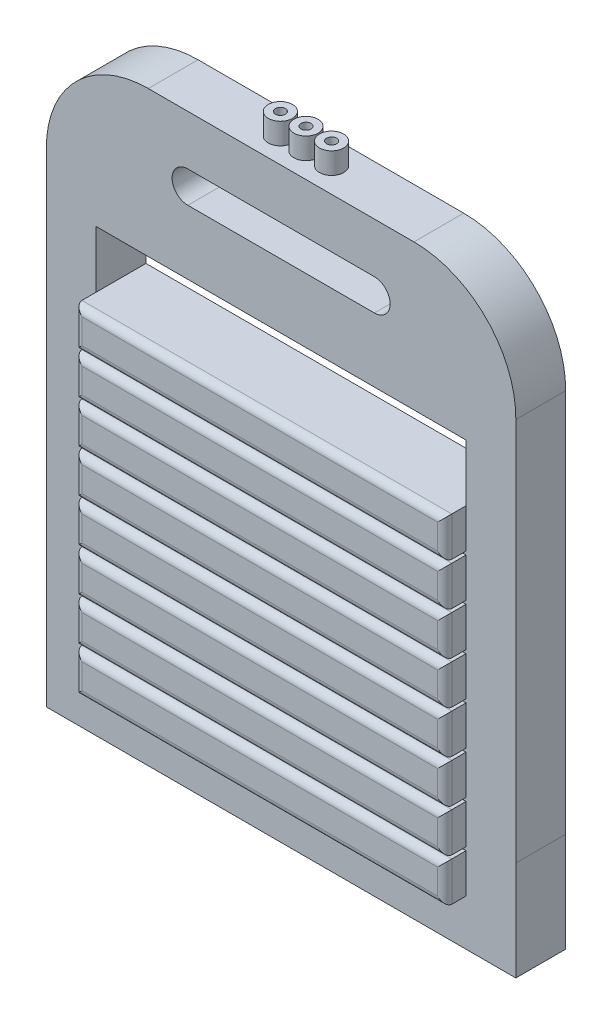
from build123d import *

# Parameters (mm, degrees)
SKETCH1_W           = 660
SKETCH1_H           = 400
BOSS_EXTRUDE1_DEPTH = 70
SKETCH2_W           = 70
SKETCH2_H           = 70
BOSS_EXTRUDE2_DEPTH = 140
SKETCH3_W           = 70
SKETCH3_H           = 60
BOSS_EXTRUDE3_DEPTH = 660
BOSS_EXTRUDE4_DEPTH = 70
SKETCH5_W           = 520
SKETCH5_H           = 55.194253578
BOSS_EXTRUDE5_DEPTH = 30
FILLET1_R           = 10
SKETCH6_R           = 17
SKETCH6_R_2         = 7
BOSS_EXTRUDE6_DEPTH = 30
SKETCH9_W           = 660.000414718
SKETCH9_H           = 140
BOSS_EXTRUDE7_DEPTH = 70
SKETCH10_W          = 520
SKETCH10_H          = 55.194253578
BOSS_EXTRUDE8_DEPTH = 30
FILLET2_R           = 10


with BuildPart() as part:
    # Sketch1 → Boss-Extrude1 (new body)
    with BuildSketch(Plane.XY):
        Rectangle(SKETCH1_W, SKETCH1_H)
    extrude(amount=BOSS_EXTRUDE1_DEPTH)

    # Sketch2 → Boss-Extrude2 (add)
    with BuildSketch(Plane(origin=(0, 200, 0), x_dir=(1, 0, 0), z_dir=(0, 1, 0))):
        with Locations((-295, -35)):
            Rectangle(SKETCH2_W, SKETCH2_H)
        with Locations((295, -35)):
            Rectangle(SKETCH2_W, SKETCH2_H)
    extrude(amount=BOSS_EXTRUDE2_DEPTH)

    # Sketch3 → Boss-Extrude3 (add)
    with BuildSketch(Plane(origin=(330, 0, 0), x_dir=(0, 0, -1), z_dir=(1, 0, 0))):
        with Locations((-35, 310)):
            Rectangle(SKETCH3_W, SKETCH3_H)
    extrude(amount=-BOSS_EXTRUDE3_DEPTH)

    # Sketch4 → Boss-Extrude4 (add)
    with BuildSketch(Plane.XY.offset(70)):
        with BuildLine():
            Line((-186.732097713, 484.618446846), (186.732097713, 484.618446846))
            ThreePointArc((186.732097713, 484.618446846), (288.516412558, 442.178022701), (330, 340))
            Line((330, 340), (-330, 340))
            ThreePointArc((-330, 340), (-288.516412558, 442.178022701), (-186.732097713, 484.618446846))
        make_face()
        with BuildLine():
            Line((-131.145584022, 414.4805226), (131.145584022, 414.4805226))
            ThreePointArc((131.145584022, 414.4805226), (153.253905114, 392.372201507), (131.145584022, 370.263880415))
            Line((131.145584022, 370.263880415), (-131.145584022, 370.263880415))
            ThreePointArc((-131.145584022, 370.263880415), (-153.253905114, 392.372201507), (-131.145584022, 414.4805226))
        make_face(mode=Mode.SUBTRACT)
    extrude(amount=-BOSS_EXTRUDE4_DEPTH)

    # Sketch5 → Boss-Extrude5 (add)
    with BuildSketch(Plane.XY.offset(70)):
        with Locations((0, 172.402873211)):
            Rectangle(SKETCH5_W, SKETCH5_H)
        with Locations((0, 112.402873211)):
            Rectangle(SKETCH5_W, SKETCH5_H)
        with Locations((0, 52.402873211)):
            Rectangle(SKETCH5_W, SKETCH5_H)
        with Locations((0, -7.597126789)):
            Rectangle(SKETCH5_W, SKETCH5_H)
        with Locations((0, -67.597126789)):
            Rectangle(SKETCH5_W, SKETCH5_H)
        with Locations((0, -127.597126789)):
            Rectangle(SKETCH5_W, SKETCH5_H)
    extrude(amount=BOSS_EXTRUDE5_DEPTH)

    # Fillet1
    fillet1_edges = [part.edges().sort_by_distance(p)[0] for p in [
        (0, 140, 100),
        (-260, 112.402873211, 100),
        (0, 84.805746422, 100),
        (260, 112.402873211, 100),
        (0, 80, 100),
        (-260, 52.402873211, 100),
        (0, 24.805746422, 100),
        (260, 52.402873211, 100),
        (0, 20, 100),
        (-260, -7.597126789, 100),
        (0, -35.194253578, 100),
        (260, -7.597126789, 100),
        (0, -40, 100),
        (-260, -67.597126789, 100),
        (0, -95.194253578, 100),
        (260, -67.597126789, 100),
        (0, -100, 100),
        (-260, -127.597126789, 100),
        (0, -155.194253578, 100),
        (260, -127.597126789, 100),
        (-260, 172.402873211, 100),
        (0, 144.805746422, 100),
        (260, 172.402873211, 100),
        (0, 200, 100),
    ]]
    fillet(fillet1_edges, radius=FILLET1_R)

    # Sketch6 → Boss-Extrude6 (add)
    with BuildSketch(Plane(origin=(0, 484.618446846, 0), x_dir=(1, 0, 0), z_dir=(0, 1, 0))):
        with Locations((-36, -35)):
            Circle(SKETCH6_R)
        with Locations((-36, -35)):
            Circle(SKETCH6_R_2, mode=Mode.SUBTRACT)
        with Locations((0, -35)):
            Circle(SKETCH6_R)
        with Locations((0, -35)):
            Circle(SKETCH6_R_2, mode=Mode.SUBTRACT)
        with Locations((36, -35)):
            Circle(SKETCH6_R)
        with Locations((36, -35)):
            Circle(SKETCH6_R_2, mode=Mode.SUBTRACT)
    extrude(amount=BOSS_EXTRUDE6_DEPTH)

    # Sketch9 → Boss-Extrude7 (add)
    with BuildSketch(Plane.XY.offset(70)):
        with Locations((0.000207359, -270)):
            Rectangle(SKETCH9_W, SKETCH9_H)
    extrude(amount=-BOSS_EXTRUDE7_DEPTH)

    # Sketch10 → Boss-Extrude8 (add)
    with BuildSketch(Plane.XY.offset(70)):
        with Locations((0, -187.597126789)):
            Rectangle(SKETCH10_W, SKETCH10_H)
        with Locations((0, -127.597126789)):
            Rectangle(SKETCH10_W, SKETCH10_H)
        with Locations((0, -247.597126789)):
            Rectangle(SKETCH10_W, SKETCH10_H)
    extrude(amount=BOSS_EXTRUDE8_DEPTH)

    # Fillet2
    fillet2_edges = [part.edges().sort_by_distance(p)[0] for p in [
        (-260, -127.597126789, 100),
        (0, -155.194253578, 100),
        (260, -127.597126789, 100),
        (0, -100, 100),
        (-260, -187.597126789, 100),
        (0, -215.194253578, 100),
        (260, -187.597126789, 100),
        (0, -160, 100),
        (-260, -247.597126789, 100),
        (0, -275.194253578, 100),
        (260, -247.597126789, 100),
        (0, -220, 100),
    ]]
    fillet(fillet2_edges, radius=FILLET2_R)


solid = part.part
